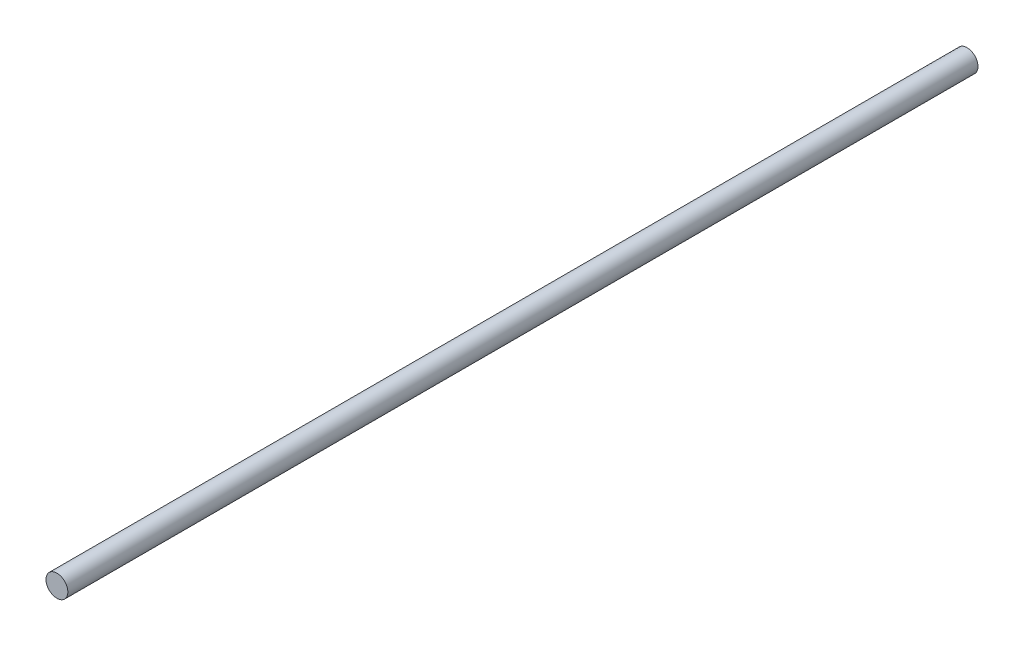
from build123d import *

# Parameters (mm, degrees)
SKETCH1_R  = 3
MAIN_DEPTH = 250


with BuildPart() as part:
    # Sketch1 → Main (new body)
    with BuildSketch(Plane.XY):
        Circle(SKETCH1_R)
    extrude(amount=MAIN_DEPTH)


solid = part.part
